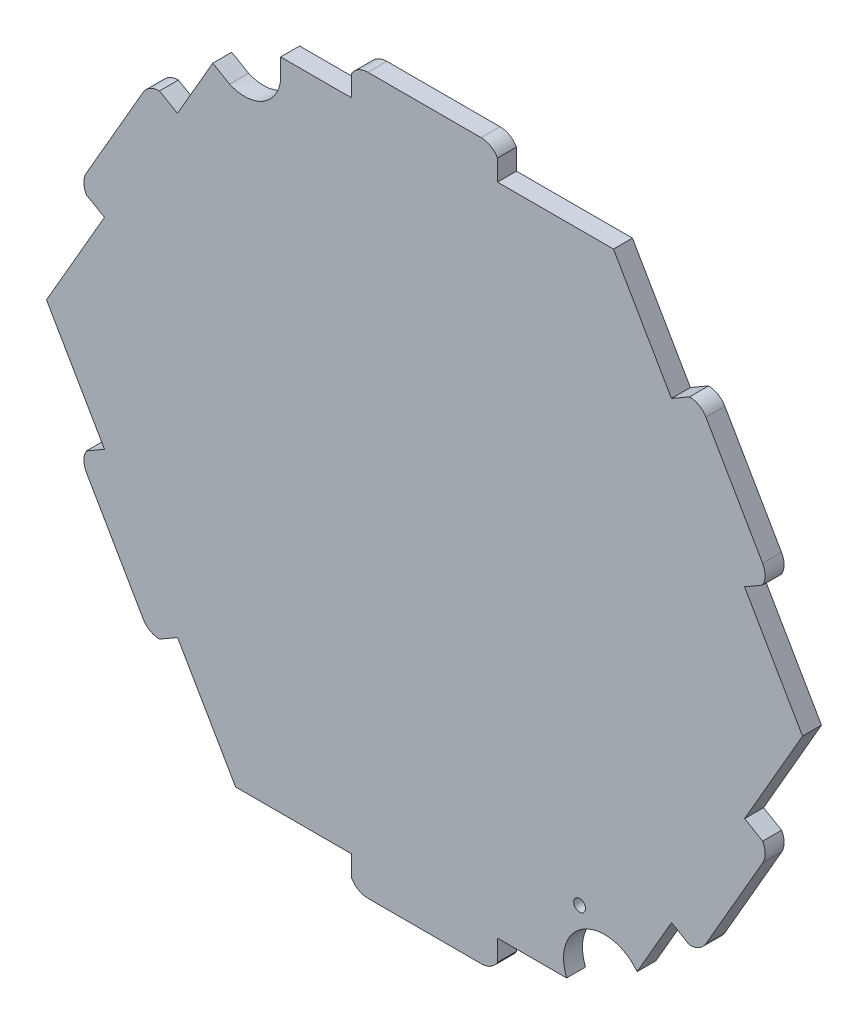
from build123d import *

# Parameters (mm, degrees)
SALIENTE_EXTRUIR1_DEPTH = 5
CROQUIS2_R              = 1.563071694
CORTAR_EXTRUIR1_DEPTH   = 10


with BuildPart() as part:
    # Croquis1 → Saliente-Extruir1 (new body)
    with BuildSketch(Plane.XY):
        with BuildLine():
            ThreePointArc((-51.415727165, 73.433311131), (-42.744189857, 73.869405728), (-37.96791411, 81.120124849))
            Line((-37.96791411, 81.120124849), (-37.96791411, 86.394261487))
            Line((-37.96791411, 86.394261487), (-19.296868546, 86.394261487))
            Line((-19.296868546, 86.394261487), (-19.296868546, 91.89912361))
            ThreePointArc((-19.296868546, 91.89912361), (-17.466810584, 93.728616325), (-14.967256479, 94.398231899))
            Line((-14.967256479, 94.398231899), (14.931670067, 94.398231899))
            ThreePointArc((14.931670067, 94.398231899), (17.431224172, 93.728616325), (19.261282134, 91.89912361))
            Line((19.261282134, 91.89912361), (19.261282134, 86.402202311))
            Line((19.261282134, 86.402202311), (49.864249238, 86.408504811))
            Line((49.864249238, 86.408504811), (65.171190916, 59.908709118))
            Line((65.171190916, 59.908709118), (69.938541359, 62.661140179))
            ThreePointArc((69.938541359, 62.661140179), (72.437957507, 61.991009851), (74.267638657, 60.161140285))
            Line((74.267638657, 60.161140285), (89.21710193, 34.267910351))
            ThreePointArc((89.21710193, 34.267910351), (89.886974885, 31.768425211), (89.217616699, 29.268802168))
            Line((89.217616699, 29.268802168), (84.457143211, 26.520341518))
            Line((84.457143211, 26.520341518), (99.764084889, 0.020545825))
            Line((99.764084889, 0.020545825), (84.468059462, -26.485552369))
            Line((84.468059462, -26.485552369), (89.235409905, -29.237983431))
            ThreePointArc((89.235409905, -29.237983431), (89.904768091, -31.737606474), (89.234895136, -34.237091613))
            Line((89.234895136, -34.237091613), (74.285431863, -60.130321548))
            ThreePointArc((74.285431863, -60.130321548), (72.455750713, -61.960191114), (69.956334565, -62.630321442))
            Line((69.956334565, -62.630321442), (65.195861077, -59.881860793))
            Line((65.195861077, -59.881860793), (56.094468632, -75.653435114))
            ThreePointArc((56.094468632, -75.653435114), (42.096374739, -72.88292625), (37.495566471, -86.390513573))
            Line((37.495566471, -86.390513573), (19.296868546, -86.394261487))
            Line((19.296868546, -86.394261487), (19.296868546, -91.89912361))
            ThreePointArc((19.296868546, -91.89912361), (17.466810584, -93.728616325), (14.967256479, -94.398231899))
            Line((14.967256479, -94.398231899), (-14.931670067, -94.398231899))
            ThreePointArc((-14.931670067, -94.398231899), (-17.431224172, -93.728616325), (-19.261282134, -91.89912361))
            Line((-19.261282134, -91.89912361), (-19.261282134, -86.402202311))
            Line((-19.261282134, -86.402202311), (-49.864249238, -86.408504811))
            Line((-49.864249238, -86.408504811), (-65.171190916, -59.908709118))
            Line((-65.171190916, -59.908709118), (-69.938541359, -62.661140179))
            ThreePointArc((-69.938541359, -62.661140179), (-72.437957507, -61.991009851), (-74.267638657, -60.161140285))
            Line((-74.267638657, -60.161140285), (-89.21710193, -34.267910351))
            ThreePointArc((-89.21710193, -34.267910351), (-89.886974885, -31.768425211), (-89.217616699, -29.268802168))
            Line((-89.217616699, -29.268802168), (-84.457143211, -26.520341518))
            Line((-84.457143211, -26.520341518), (-99.764084889, -0.020545825))
            Line((-99.764084889, -0.020545825), (-84.468059462, 26.485552369))
            Line((-84.468059462, 26.485552369), (-89.235409905, 29.237983431))
            ThreePointArc((-89.235409905, 29.237983431), (-89.904768091, 31.737606474), (-89.234895136, 34.237091613))
            Line((-89.234895136, 34.237091613), (-74.285431863, 60.130321548))
            ThreePointArc((-74.285431863, 60.130321548), (-72.455750713, 61.960191114), (-69.956334565, 62.630321442))
            Line((-69.956334565, 62.630321442), (-65.195861077, 59.881860793))
            Line((-65.195861077, 59.881860793), (-55.88668677, 76.013702989))
            Line((-55.88668677, 76.013702989), (-51.415727165, 73.433311131))
        make_face()
    extrude(amount=SALIENTE_EXTRUIR1_DEPTH)

    # Croquis2 → Cortar-Extruir1 (cut)
    with BuildSketch(Plane.XY.offset(5)):
        with Locations((40.934728827, -68.058233997)):
            Circle(CROQUIS2_R)
    extrude(amount=-CORTAR_EXTRUIR1_DEPTH, mode=Mode.SUBTRACT)


solid = part.part
